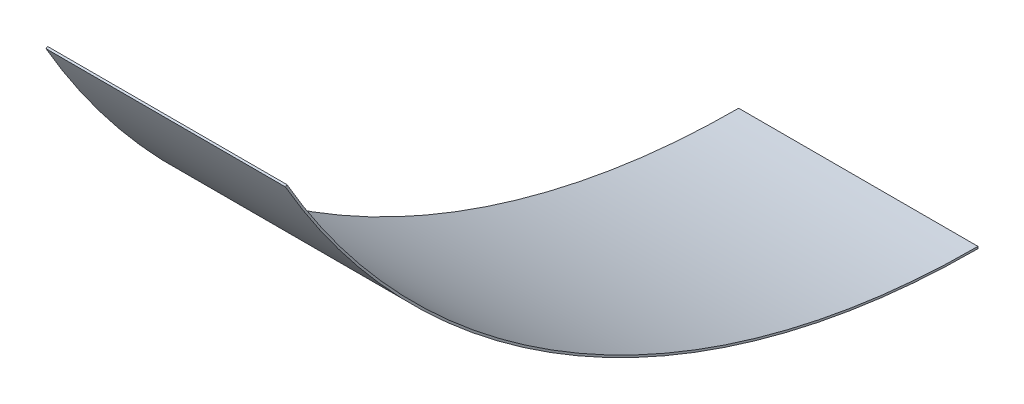
from build123d import *

# Parameters (mm, degrees)
SKETCH1_W      = 15.24
SKETCH1_H      = 0.127
REVOLVE1_ANGLE = 60


with BuildPart() as part:
    # Sketch1 → Revolve1 (revolve)
    with BuildSketch(Plane.XY):
        with Locations((-7.62, 0.0635)):
            Rectangle(SKETCH1_W, SKETCH1_H)
    revolve(axis=Axis((0, 50.935947988, 0), (-1, 0, 0)), revolution_arc=REVOLVE1_ANGLE)


solid = part.part
